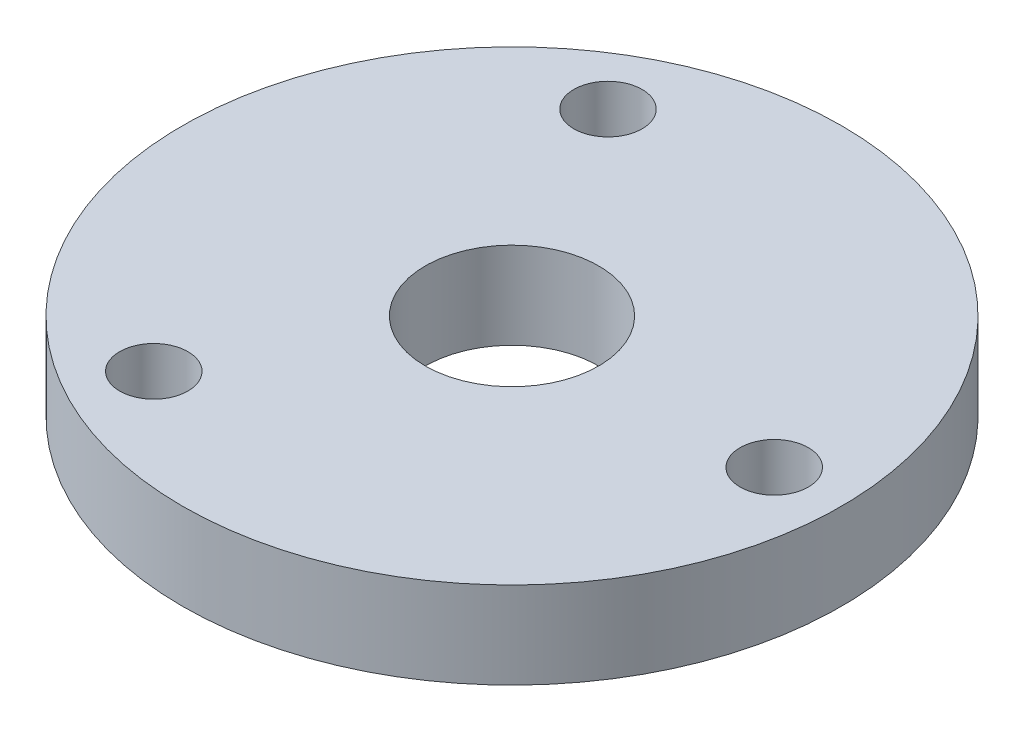
from build123d import *

# Parameters (mm, degrees)
SKETCH1_R           = 24.13
SKETCH1_R_2         = 2.5
SKETCH1_R_3         = 6.35
BOSS_EXTRUDE1_DEPTH = 6.35


with BuildPart() as part:
    # Sketch1 → Boss-Extrude1 (new body)
    with BuildSketch(Plane(origin=(0, 0, 0), x_dir=(1, 0, 0), z_dir=(0, 1, 0))):
        Circle(SKETCH1_R)
        with Locations((19.2, 0)):
            Circle(SKETCH1_R_2, mode=Mode.SUBTRACT)
        with Locations((-9.6, 16.627687753)):
            Circle(SKETCH1_R_2, mode=Mode.SUBTRACT)
        with Locations((-9.6, -16.627687753)):
            Circle(SKETCH1_R_2, mode=Mode.SUBTRACT)
        Circle(SKETCH1_R_3, mode=Mode.SUBTRACT)
    extrude(amount=BOSS_EXTRUDE1_DEPTH)


solid = part.part
